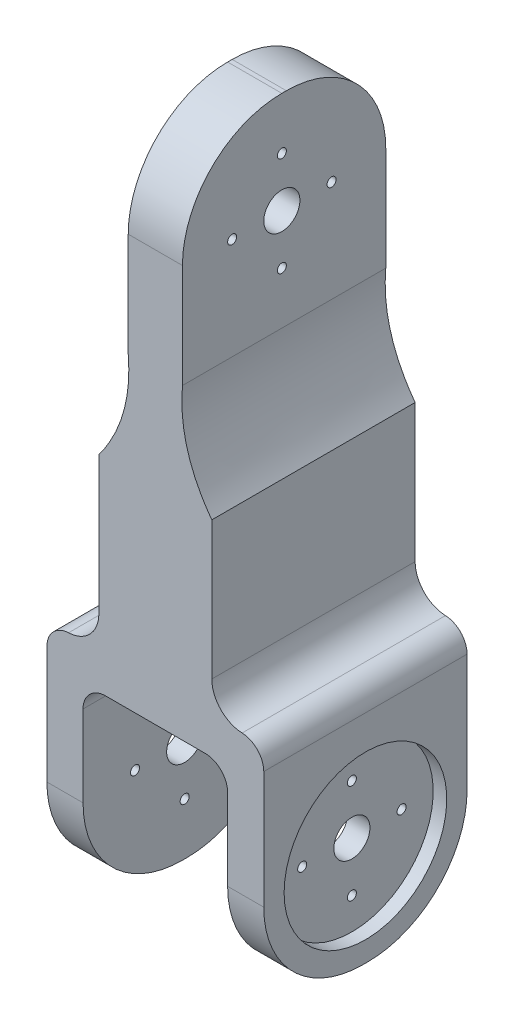
from build123d import *

# Parameters (mm, degrees)
SKETCH2_W           = 48
SKETCH2_H           = 45
BOSS_EXTRUDE1_DEPTH = 8
BOSS_EXTRUDE2_DEPTH = 8
CUT_EXTRUDE1_START  = -8
SKETCH4_R           = 18
CUT_EXTRUDE1_DEPTH  = 3
SKETCH5_R           = 4
SKETCH5_R_2         = 1
CUT_EXTRUDE2_DEPTH  = 46
SKETCH6_W           = 25
SKETCH6_H           = 45
BOSS_EXTRUDE3_DEPTH = 60
FILLET7_R           = 5
SKETCH7_W           = 12
SKETCH7_H           = 45
BOSS_EXTRUDE4_DEPTH = 45
FILLET10_R          = 22
SKETCH8_R           = 18
CUT_EXTRUDE3_DEPTH  = 3
SKETCH9_R           = 4
SKETCH9_R_2         = 1
CUT_EXTRUDE4_DEPTH  = 28
CUT_EXTRUDE5_DEPTH  = 46
FILLET11_R          = 5
FILLET12_R          = 7


with BuildPart() as part:
    # Sketch2 → Boss-Extrude1 (new body)
    with BuildSketch(Plane(origin=(0, 0, 0), x_dir=(1, 0, 0), z_dir=(0, 1, 0))):
        Rectangle(SKETCH2_W, SKETCH2_H)
    extrude(amount=BOSS_EXTRUDE1_DEPTH)

    # Sketch3 → Boss-Extrude2 (add)
    with BuildSketch(Plane(origin=(24, 0, 0), x_dir=(0, 0, -1), z_dir=(1, 0, 0))):
        with BuildLine():
            Line((-22.5, 0), (22.5, 0))
            Line((22.5, 0), (22.5, -23))
            ThreePointArc((22.5, -23), (16.056349186, -38.556349186), (0.5, -45))
            Line((0.5, -45), (-0.5, -45))
            ThreePointArc((-0.5, -45), (-16.056349186, -38.556349186), (-22.5, -23))
            Line((-22.5, -23), (-22.5, 0))
        make_face()
    extrude(amount=-BOSS_EXTRUDE2_DEPTH)

    # Sketch4 → Cut-Extrude1 (cut)
    with BuildSketch(Plane.ZY.offset(-16).offset(CUT_EXTRUDE1_START)):
        with Locations((0, -22.5)):
            Circle(SKETCH4_R)
    extrude(amount=CUT_EXTRUDE1_DEPTH, mode=Mode.SUBTRACT)

    # Sketch5 → Cut-Extrude2 (cut, through all)
    with BuildSketch(Plane(origin=(21, 0, 0), x_dir=(0, 0, -1), z_dir=(1, 0, 0))):
        with Locations((0, -22.5)):
            Circle(SKETCH5_R)
        with Locations((0, -11.5)):
            Circle(SKETCH5_R_2)
        with Locations((11, -22.5)):
            Circle(SKETCH5_R_2)
        with Locations((0, -33.5)):
            Circle(SKETCH5_R_2)
        with Locations((-11, -22.5)):
            Circle(SKETCH5_R_2)
    extrude(amount=-CUT_EXTRUDE2_DEPTH, mode=Mode.SUBTRACT)

    # Mirror1: part across plane


with BuildPart() as part_1:
    add(part.part)
    add(part.part.mirror(Plane(origin=(0, 0, 0), x_dir=(0, 0, 1), z_dir=(1, 0, 0))))

    # Sketch6 → Boss-Extrude3 (add)
    with BuildSketch(Plane(origin=(0, 8, 0), x_dir=(1, 0, 0), z_dir=(0, 1, 0))):
        Rectangle(SKETCH6_W, SKETCH6_H)
    extrude(amount=BOSS_EXTRUDE3_DEPTH)

    # Fillet7
    fillet7_edges = [part_1.edges().sort_by_distance(p)[0] for p in [
        (16, 0, 0),
        (-16, 0, 0),
    ]]
    fillet(fillet7_edges, radius=FILLET7_R)

    # Sketch7 → Boss-Extrude4 (add)
    with BuildSketch(Plane(origin=(0, 68, 0), x_dir=(1, 0, 0), z_dir=(0, 1, 0))):
        Rectangle(SKETCH7_W, SKETCH7_H)
    extrude(amount=BOSS_EXTRUDE4_DEPTH)

    # Fillet10
    fillet10_edges = [part_1.edges().sort_by_distance(p)[0] for p in [
        (0, 113, -22.5),
        (0, 113, 22.5),
    ]]
    fillet(fillet10_edges, radius=FILLET10_R)

    # Sketch8 → Cut-Extrude3 (cut)
    with BuildSketch(Plane.ZY.offset(6)):
        with Locations((0.5, 90.5)):
            Circle(SKETCH8_R)
    extrude(amount=-CUT_EXTRUDE3_DEPTH, mode=Mode.SUBTRACT)

    # Sketch9 → Cut-Extrude4 (cut, through all)
    with BuildSketch(Plane.ZY.offset(3)):
        with Locations((0.5, 90.5)):
            Circle(SKETCH9_R)
        with Locations((0.5, 101.5)):
            Circle(SKETCH9_R_2)
        with Locations((11.5, 90.5)):
            Circle(SKETCH9_R_2)
        with Locations((0.5, 79.5)):
            Circle(SKETCH9_R_2)
        with Locations((-10.5, 90.5)):
            Circle(SKETCH9_R_2)
    extrude(amount=-CUT_EXTRUDE4_DEPTH, mode=Mode.SUBTRACT)

    # Sketch10 → Cut-Extrude5 (cut, through all)
    with BuildSketch(Plane(origin=(0, 0, -22.5), x_dir=(-1, 0, 0), z_dir=(0, 0, -1))):
        with BuildLine():
            Line((12.5, 68), (6, 68))
            add(Edge.make_bspline(
                [(6, 68), (4.938641011, 55.683018677), (12.5, 45.493141657)],
                knots=[0, 0, 0, 1, 1, 1], degree=2))
            Line((12.5, 45.493141657), (12.5, 68))
        make_face()
        with BuildLine():
            Line((-6, 68), (-12.5, 68))
            Line((-12.5, 68), (-12.5, 45.493141657))
            add(Edge.make_bspline(
                [(-6, 68), (-4.938641011, 55.683018677), (-12.5, 45.493141657)],
                knots=[0, 0, 0, 1, 1, 1], degree=2))
        make_face()
    extrude(amount=-CUT_EXTRUDE5_DEPTH, mode=Mode.SUBTRACT)

    # Fillet11
    fillet11_edges = [part_1.edges().sort_by_distance(p)[0] for p in [
        (24, 8, 0),
        (-24, 8, 0),
    ]]
    fillet(fillet11_edges, radius=FILLET11_R)

    # Fillet12
    fillet12_edges = [part_1.edges().sort_by_distance(p)[0] for p in [
        (-12.5, 8, 0),
        (12.5, 8, 0),
    ]]
    fillet(fillet12_edges, radius=FILLET12_R)


solid = part_1.part
